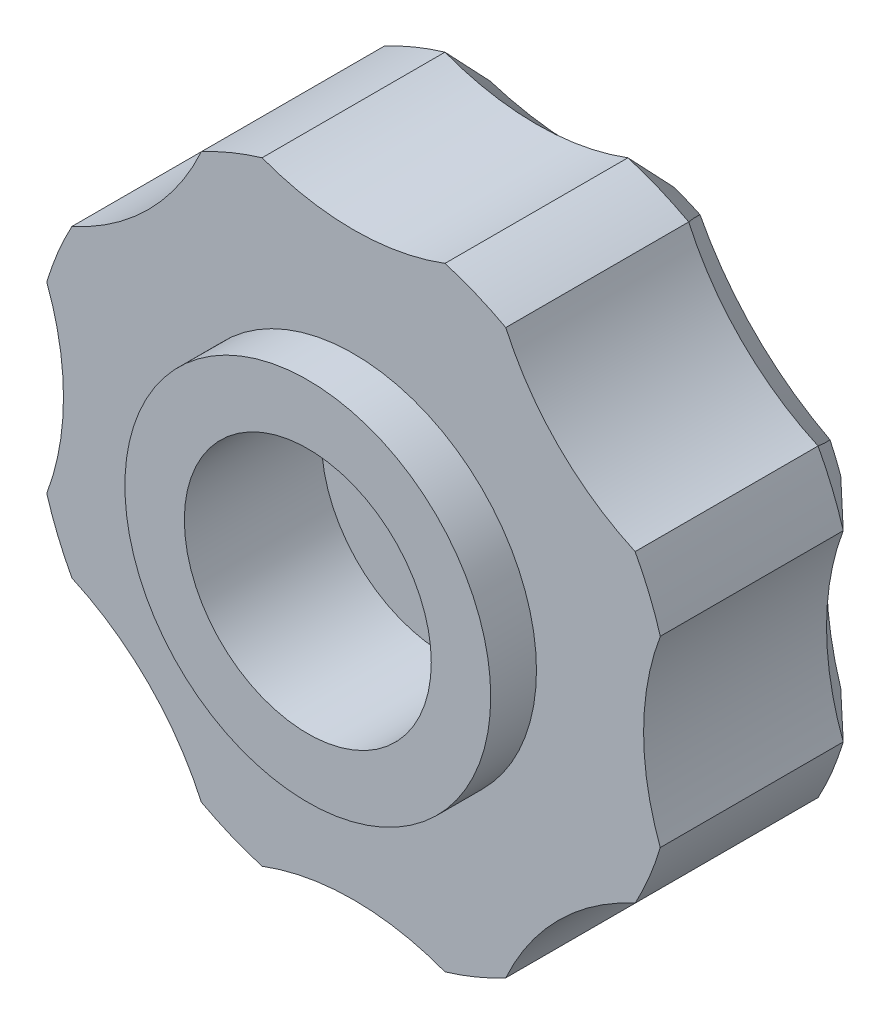
from build123d import *

# Parameters (mm, degrees)
ESQUISSE1_R                  = 7
BOSS_EXTRU_1_DEPTH           = 5
ENL_V_MAT_EXTRU_2_DEPTH      = 6
R_P_TITION_CIRCULAIRE1_COUNT = 8
CHANFREIN1_SIZE              = 1
ESQUISSE3_R                  = 4
BOSS_EXTRU_2_DEPTH           = 1
ESQUISSE4_R                  = 2.7
ENL_V_MAT_EXTRU_3_DEPTH      = 3


with BuildPart() as part:
    # Esquisse1 → Boss.-Extru.1 (new body)
    with BuildSketch(Plane.XY):
        Circle(ESQUISSE1_R)
    extrude(amount=BOSS_EXTRU_1_DEPTH)

    # Esquisse2 → Enlèv. mat.-Extru.2 (cut, through all)
    with BuildSketch(Plane.XY.offset(5)):
        with BuildLine():
            ThreePointArc((2, 6.708203932), (0, 6.342871257), (-2, 6.708203932))
            ThreePointArc((-2, 6.708203932), (0, 7), (2, 6.708203932))
        make_face()
    enl_v_mat_extru_2 = extrude(amount=-ENL_V_MAT_EXTRU_2_DEPTH, mode=Mode.SUBTRACT)

    # Répétition circulaire1: Enlèv. mat.-Extru.2 ×8 about axis
    r_p_tition_circulaire1_axis = Axis((0, 0, 0), (0, 0, 1))
    for i in range(1, R_P_TITION_CIRCULAIRE1_COUNT):
        add(enl_v_mat_extru_2.rotate(r_p_tition_circulaire1_axis, i * 360 / R_P_TITION_CIRCULAIRE1_COUNT), mode=Mode.SUBTRACT)

    # Chanfrein1
    chanfrein1_edges = [part.edges().sort_by_distance(p)[0] for p in [
        (-6.467156728, 2.678784027, 0),
        (-6.467156728, -2.678784027, 0),
        (-2.678784027, -6.467156728, 0),
        (2.678784027, -6.467156728, 0),
        (6.467156728, -2.678784027, 0),
        (6.467156728, 2.678784027, 0),
        (2.678784027, 6.467156728, 0),
        (-6.342871257, 0, 0),
        (-4.485087278, -4.485087278, 0),
        (0, -6.342871257, 0),
        (4.485087278, -4.485087278, 0),
        (6.342871257, 0, 0),
        (4.485087278, 4.485087278, 0),
        (-2.678784027, 6.467156728, 0),
        (-4.485087278, 4.485087278, 0),
        (0, 6.342871257, 0),
    ]]
    chamfer(chanfrein1_edges, length=CHANFREIN1_SIZE)

    # Esquisse3 → Boss.-Extru.2 (add)
    with BuildSketch(Plane.XY.offset(5)):
        Circle(ESQUISSE3_R)
    extrude(amount=BOSS_EXTRU_2_DEPTH)

    # Esquisse4 → Enlèv. mat.-Extru.3 (cut)
    with BuildSketch(Plane.XY.offset(6)):
        Circle(ESQUISSE4_R)
    extrude(amount=-ENL_V_MAT_EXTRU_3_DEPTH, mode=Mode.SUBTRACT)


solid = part.part
